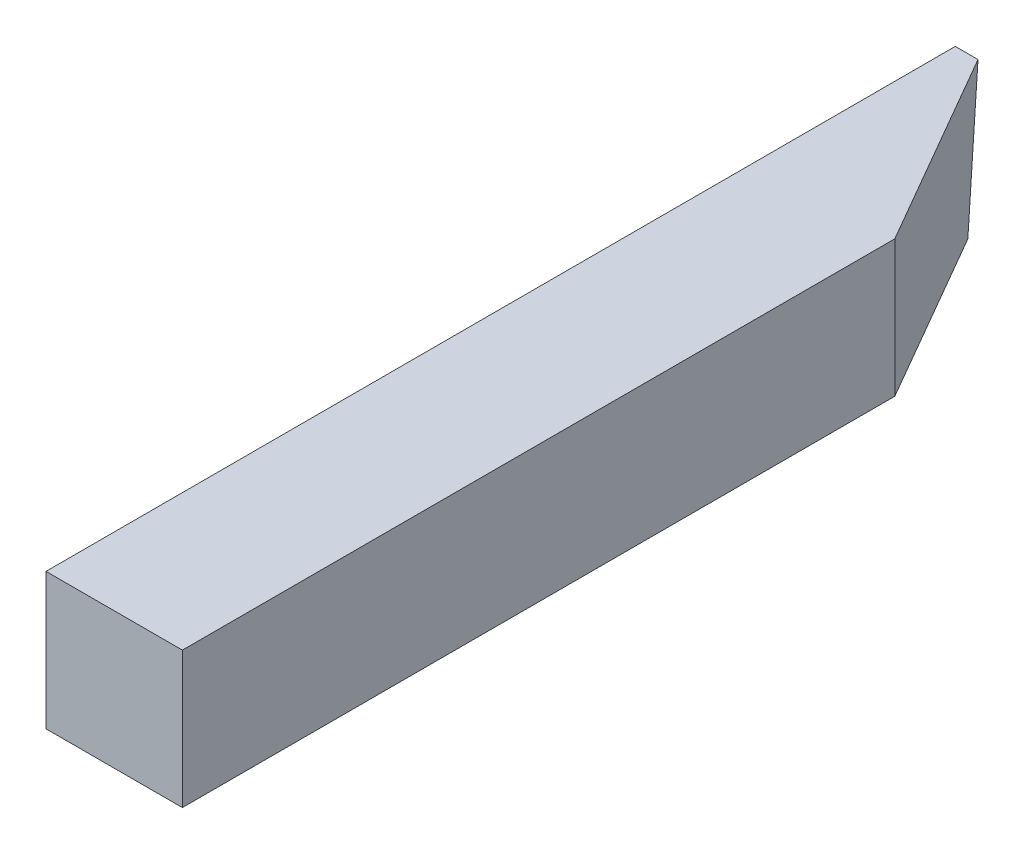
from build123d import *

# Parameters (mm, degrees)
BOSS_EXTRUDE1_DEPTH = 9.525
CUT_EXTRUDE1_DEPTH  = 9.525


with BuildPart() as part:
    # Sketch1 → Boss-Extrude1 (new body)
    with BuildSketch(Plane(origin=(0, 0, 0), x_dir=(1, 0, 0), z_dir=(0, 1, 0))):
        Polygon((0, 0), (0, 49.751846715), (-7.9375, 63.5), (-9.525, 63.5), (-9.525, 0), align=None)
    extrude(amount=BOSS_EXTRUDE1_DEPTH)

    # Sketch2 → Cut-Extrude1 (cut)
    with BuildSketch(Plane(origin=(0, 0, 0), x_dir=(0, 0, -1), z_dir=(1, 0, 0))):
        Polygon((63.5, 9.525), (61.820485509, 0), (63.5, 0), align=None)
    extrude(amount=-CUT_EXTRUDE1_DEPTH, mode=Mode.SUBTRACT)


solid = part.part
